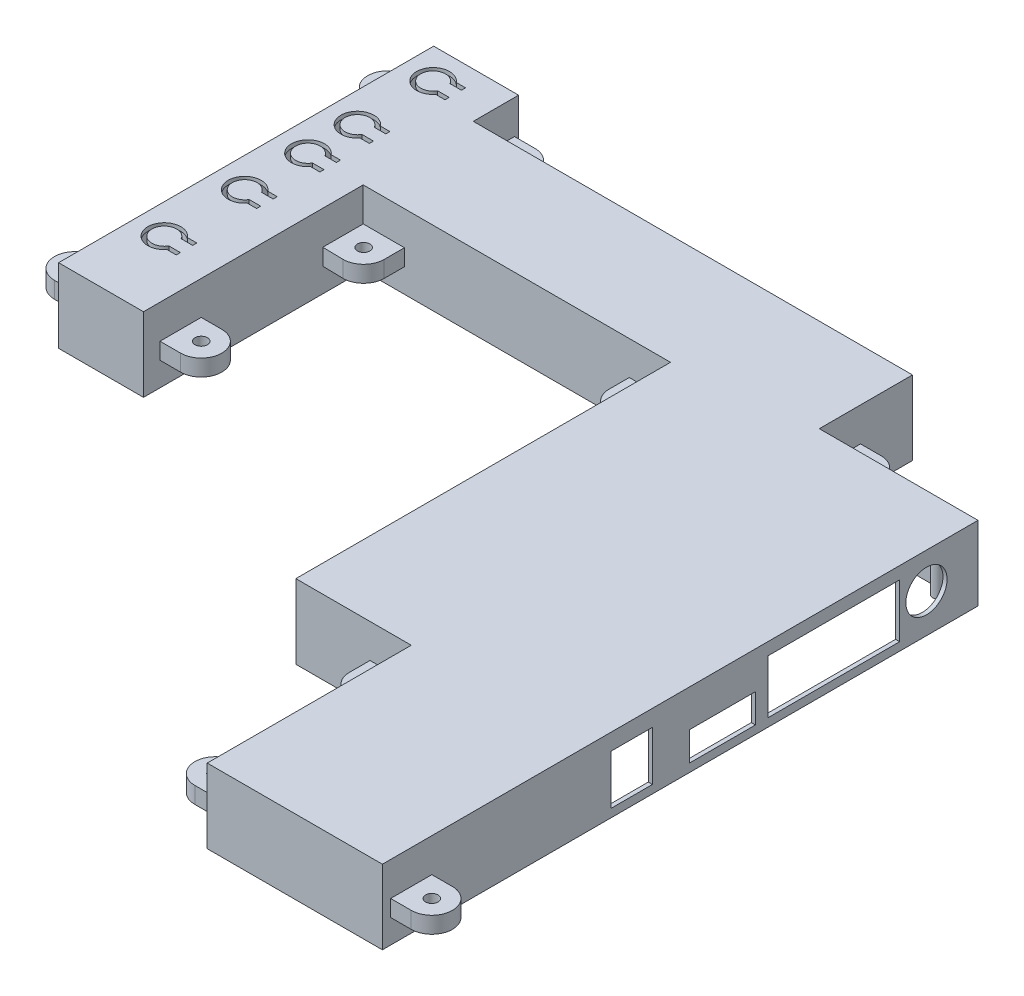
from build123d import *

# Parameters (mm, degrees)
BOSS_EXTRUDE5_DEPTH     = 18
BOSS_EXTRUDE6_START     = 17
BOSS_EXTRUDE6_DEPTH     = 1
BOSS_EXTRUDE7_START     = 5.8
SKETCH2_5_R             = 1.5
BOSS_EXTRUDE7_DEPTH     = 4
CUT_EXTRUDE1_DEPTH      = 167.833614155
CUT_EXTRUDE1_DEPTH_BACK = 167.833614155
BOSS_EXTRUDE9_START     = -1
SKETCH6_R               = 3.5
SKETCH6_R_2             = 2.25
BOSS_EXTRUDE9_DEPTH     = 6
SKETCH8_R               = 5
SKETCH8_W               = 32
SKETCH8_H               = 13
SKETCH8_W_2             = 16
SKETCH8_H_2             = 7
SKETCH8_W_3             = 10
SKETCH8_H_3             = 12
CUT_EXTRUDE2_DEPTH      = 218.268839312
CUT_EXTRUDE2_DEPTH_BACK = 6
SKETCH7_R               = 1.2
SKETCH7_R_2             = 3
SKETCH7_R_3             = 2
BOSS_EXTRUDE10_DEPTH    = 15


with BuildPart() as part:
    # Sketch2 → Boss-Extrude5 (new body)
    with BuildSketch(Plane(origin=(0, 0, 0), x_dir=(1, 0, 0), z_dir=(0, 1, 0))):
        Polygon((-76.553603822, 35.6), (-97.153603822, 35.6), (-97.153603822, 126.6), (-76.553603822, 126.6), (-76.553603822, 115.6), (30, 115.6), (30, 93), (68.5, 93), (68.5, -51.5), (26, -51.5), (26, -2), (-2, -2), (-2, 88.898979486), (-76.553603822, 88.898979486), align=None)
        Polygon((-77.553603822, 89.898979486), (-77.553603822, 36.6), (-96.157091143, 36.6), (-96.157091143, 125.6), (-77.553603822, 125.6), (-77.553603822, 114.6), (29, 114.6), (29, 92), (67.5, 92), (67.5, -50.5), (27, -50.5), (27, -1), (-1, -1), (-1, 89.898979486), align=None, mode=Mode.SUBTRACT)
    extrude(amount=BOSS_EXTRUDE5_DEPTH)

    # Sketch2_4 → Boss-Extrude6 (add)
    with BuildSketch(Plane(origin=(0, 0, 0), x_dir=(1, 0, 0), z_dir=(0, 1, 0)).offset(BOSS_EXTRUDE6_START)):
        Polygon((-77.553603822, 36.6), (-96.157091143, 36.6), (-96.157091143, 125.6), (-77.553603822, 125.6), (-77.553603822, 114.6), (29, 114.6), (29, 92), (67.5, 92), (67.5, -50.5), (27, -50.5), (27, -1), (-1, -1), (-1, 89.898979486), (-77.553603822, 89.898979486), align=None)
    extrude(amount=BOSS_EXTRUDE6_DEPTH)

    # Sketch2_5 → Boss-Extrude7 (add)
    with BuildSketch(Plane(origin=(0, 0, 0), x_dir=(1, 0, 0), z_dir=(0, 1, 0)).offset(BOSS_EXTRUDE7_START)):
        with BuildLine():
            Line((-102.153603822, 39.6), (-97.153603822, 39.6))
            Line((-97.153603822, 39.6), (-97.153603822, 49.6))
            Line((-97.153603822, 49.6), (-102.153603822, 49.6))
            ThreePointArc((-102.153603822, 49.6), (-107.153603822, 44.6), (-102.153603822, 39.6))
        make_face()
        with Locations(Location((-102.153603822, 44.6, 0), (0, 0, 270))):
            Circle(SKETCH2_5_R, mode=Mode.SUBTRACT)
        with BuildLine():
            Line((-76.553603822, 49.6), (-76.553603822, 39.6))
            Line((-76.553603822, 39.6), (-71.553603822, 39.6))
            ThreePointArc((-71.553603822, 39.6), (-66.553603822, 44.6), (-71.553603822, 49.6))
            Line((-71.553603822, 49.6), (-76.553603822, 49.6))
        make_face()
        with Locations(Location((-71.553603822, 44.6, 0), (0, 0, 270))):
            Circle(SKETCH2_5_R, mode=Mode.SUBTRACT)
        with BuildLine():
            Line((-76.553603822, 88.898979486), (-76.553603822, 79.101020514))
            Line((-76.553603822, 79.101020514), (-71.755562411, 79.004080392))
            Line((-71.755562411, 79.004080392), (-71.553603822, 79))
            ThreePointArc((-71.553603822, 79), (-68.018069917, 80.464466094), (-66.553603822, 84))
            Line((-66.553603822, 84), (-66.553603822, 88.898979486))
            Line((-66.553603822, 88.898979486), (-76.553603822, 88.898979486))
        make_face()
        with Locations(Location((-71.553603822, 84, 0), (0, 0, 270))):
            Circle(SKETCH2_5_R, mode=Mode.SUBTRACT)
        with BuildLine():
            Line((-2, 88.898979486), (-12, 88.898979486))
            Line((-12, 88.898979486), (-12, 84))
            ThreePointArc((-12, 84), (-10.535533906, 80.464466094), (-7, 79))
            Line((-7, 79), (-2, 79))
            Line((-2, 79), (-2, 88.898979486))
        make_face()
        with Locations(Location((-7, 84, 0), (0, 0, 270))):
            Circle(SKETCH2_5_R, mode=Mode.SUBTRACT)
        with BuildLine():
            Line((26, -2), (16, -2))
            Line((16, -2), (16, -7))
            ThreePointArc((16, -7), (17.464466094, -10.535533906), (21, -12))
            Line((21, -12), (26, -12))
            Line((26, -12), (26, -2))
        make_face()
        with Locations(Location((21, -7, 0), (0, 0, 270))):
            Circle(SKETCH2_5_R, mode=Mode.SUBTRACT)
        with BuildLine():
            Line((26, -49.5), (26, -39.5))
            Line((26, -39.5), (21, -39.5))
            ThreePointArc((21, -39.5), (16, -44.5), (21, -49.5))
            Line((21, -49.5), (26, -49.5))
        make_face()
        with Locations(Location((21, -44.5, 0), (0, 0, 270))):
            Circle(SKETCH2_5_R, mode=Mode.SUBTRACT)
        with BuildLine():
            Line((73.5, -39.5), (68.5, -39.5))
            Line((68.5, -39.5), (68.5, -49.5))
            Line((68.5, -49.5), (73.5, -49.5))
            ThreePointArc((73.5, -49.5), (78.5, -44.5), (73.5, -39.5))
        make_face()
        with Locations(Location((73.5, -44.5, 0), (0, 0, 270))):
            Circle(SKETCH2_5_R, mode=Mode.SUBTRACT)
        with BuildLine():
            Line((35, 103), (30, 103))
            Line((30, 103), (30, 93))
            Line((30, 93), (40, 93))
            Line((40, 93), (40, 98))
            ThreePointArc((40, 98), (38.535533906, 101.535533906), (35, 103))
        make_face()
        with Locations(Location((35, 98, 0), (0, 0, 270))):
            Circle(SKETCH2_5_R, mode=Mode.SUBTRACT)
        with BuildLine():
            Line((-102.153603822, 115.6), (-97.153603822, 115.6))
            Line((-97.153603822, 115.6), (-97.153603822, 125.6))
            Line((-97.153603822, 125.6), (-102.153603822, 125.6))
            ThreePointArc((-102.153603822, 125.6), (-107.153603822, 120.6), (-102.153603822, 115.6))
        make_face()
        with Locations(Location((-102.153603822, 120.6, 0), (0, 0, 270))):
            Circle(SKETCH2_5_R, mode=Mode.SUBTRACT)
        with BuildLine():
            Line((-71.553603822, 125.6), (-76.553603822, 125.6))
            Line((-76.553603822, 125.6), (-76.553603822, 115.6))
            Line((-76.553603822, 115.6), (-66.553603822, 115.6))
            Line((-66.553603822, 115.6), (-66.553603822, 120.6))
            ThreePointArc((-66.553603822, 120.6), (-68.018069917, 124.135533906), (-71.553603822, 125.6))
        make_face()
        with Locations(Location((-71.553603822, 120.6, 0), (0, 0, 270))):
            Circle(SKETCH2_5_R, mode=Mode.SUBTRACT)
        with Locations((73.5, 84)):
            Circle(SKETCH2_5_R)
    extrude(amount=BOSS_EXTRUDE7_DEPTH)


with BuildPart() as boss_extrude7_kept_piece:
    # of the separate pieces the step leaves, the one the design keeps (boss_extrude7_pieces_kept)
    add(part.part.solids().sort_by_distance((-76.553603822, 0, -35.6))[0])

    # Sketch5 → Cut-Extrude1 (cut, two sides)
    with BuildSketch(Plane(origin=(0, 18, 0), x_dir=(1, 0, 0), z_dir=(0, 1, 0))) as cut_extrude1_sk:
        with BuildLine():
            Line((-86.781104823, 121.7), (-84.514671921, 121.7))
            Line((-84.514671921, 121.7), (-84.514671921, 120.7))
            Line((-84.514671921, 120.7), (-87.305527611, 120.7))
            ThreePointArc((-87.305527611, 120.7), (-92.903603822, 119.2), (-87.305527611, 117.7))
            Line((-87.305527611, 117.7), (-84.514671921, 117.7))
            Line((-84.514671921, 117.7), (-84.514671921, 116.7))
            Line((-84.514671921, 116.7), (-86.781104823, 116.7))
            ThreePointArc((-86.781104823, 116.7), (-93.903603822, 119.2), (-86.781104823, 121.7))
        make_face()
        with BuildLine():
            Line((-86.781104823, 103.35), (-84.514671921, 103.35))
            Line((-84.514671921, 103.35), (-84.514671921, 102.35))
            Line((-84.514671921, 102.35), (-87.305527611, 102.35))
            ThreePointArc((-87.305527611, 102.35), (-92.903603822, 100.85), (-87.305527611, 99.35))
            Line((-87.305527611, 99.35), (-84.514671921, 99.35))
            Line((-84.514671921, 99.35), (-84.514671921, 98.35))
            Line((-84.514671921, 98.35), (-86.781104823, 98.35))
            ThreePointArc((-86.781104823, 98.35), (-93.903603822, 100.85), (-86.781104823, 103.35))
        make_face()
        with BuildLine():
            Line((-86.781104823, 91.35), (-84.514671921, 91.35))
            Line((-84.514671921, 91.35), (-84.514671921, 90.35))
            Line((-84.514671921, 90.35), (-87.305527611, 90.35))
            ThreePointArc((-87.305527611, 90.35), (-92.903603822, 88.85), (-87.305527611, 87.35))
            Line((-87.305527611, 87.35), (-84.514671921, 87.35))
            Line((-84.514671921, 87.35), (-84.514671921, 86.35))
            Line((-84.514671921, 86.35), (-86.781104823, 86.35))
            ThreePointArc((-86.781104823, 86.35), (-93.903603822, 88.85), (-86.781104823, 91.35))
        make_face()
        with BuildLine():
            Line((-86.781104823, 76), (-84.514671921, 76))
            Line((-84.514671921, 76), (-84.514671921, 75))
            Line((-84.514671921, 75), (-87.305527611, 75))
            ThreePointArc((-87.305527611, 75), (-92.903603822, 73.5), (-87.305527611, 72))
            Line((-87.305527611, 72), (-84.514671921, 72))
            Line((-84.514671921, 72), (-84.514671921, 71))
            Line((-84.514671921, 71), (-86.781104823, 71))
            ThreePointArc((-86.781104823, 71), (-93.903603822, 73.5), (-86.781104823, 76))
        make_face()
        with BuildLine():
            Line((-86.781104823, 56.5), (-84.514671921, 56.5))
            Line((-84.514671921, 56.5), (-84.514671921, 55.5))
            Line((-84.514671921, 55.5), (-87.305527611, 55.5))
            ThreePointArc((-87.305527611, 55.5), (-92.903603822, 54), (-87.305527611, 52.5))
            Line((-87.305527611, 52.5), (-84.514671921, 52.5))
            Line((-84.514671921, 52.5), (-84.514671921, 51.5))
            Line((-84.514671921, 51.5), (-86.781104823, 51.5))
            ThreePointArc((-86.781104823, 51.5), (-93.903603822, 54), (-86.781104823, 56.5))
        make_face()
    extrude(amount=CUT_EXTRUDE1_DEPTH, mode=Mode.SUBTRACT)
    extrude(cut_extrude1_sk.sketch, amount=-CUT_EXTRUDE1_DEPTH_BACK, mode=Mode.SUBTRACT)

    # Sketch6 → Boss-Extrude9 (add)
    with BuildSketch(Plane(origin=(0, 18, 0), x_dir=(1, 0, 0), z_dir=(0, 1, 0)).offset(BOSS_EXTRUDE9_START)):
        with Locations(Location((-89.903603822, 109.25, 0), (0, 0, 270))):
            Circle(SKETCH6_R)
        with Locations(Location((-89.903603822, 109.25, 0), (0, 0, 270))):
            Circle(SKETCH6_R_2, mode=Mode.SUBTRACT)
        with Locations(Location((-89.903603822, 63, 0), (0, 0, 270))):
            Circle(SKETCH6_R)
        with Locations(Location((-89.903603822, 63, 0), (0, 0, 270))):
            Circle(SKETCH6_R_2, mode=Mode.SUBTRACT)
    extrude(amount=-BOSS_EXTRUDE9_DEPTH)

    # Sketch8 → Cut-Extrude2 (cut, two sides)
    with BuildSketch(Plane(origin=(68.5, 0, 0), x_dir=(0, 0, -1), z_dir=(1, 0, 0))) as cut_extrude2_sk:
        with Locations((80.5, 9.4)):
            Circle(SKETCH8_R)
        with Locations((58, 8.5)):
            Rectangle(SKETCH8_W, SKETCH8_H)
        with Locations((31, 5.5)):
            Rectangle(SKETCH8_W_2, SKETCH8_H_2)
        with Locations((9, 8)):
            Rectangle(SKETCH8_W_3, SKETCH8_H_3)
    extrude(amount=CUT_EXTRUDE2_DEPTH, mode=Mode.SUBTRACT)
    extrude(cut_extrude2_sk.sketch, amount=-CUT_EXTRUDE2_DEPTH_BACK, mode=Mode.SUBTRACT)

    # Sketch7 → Boss-Extrude10 (add)
    with BuildSketch(Plane.XZ.offset(-17)):
        with Locations(Location((1.2, -10.7, 0), (0, 0, 90))):
            Circle(SKETCH7_R)
        with Locations(Location((2, -89, 0), (0, 0, 90))):
            Circle(SKETCH7_R)
        with Locations(Location((63.3, -88.4, 0), (0, 0, 90))):
            Circle(SKETCH7_R)
        with Locations(Location((63, -1.6, 0), (0, 0, 90))):
            Circle(SKETCH7_R)
        with Locations(Location((52.066768514, -32.967079536, 0), (0, 0, 90))):
            Circle(SKETCH7_R_2)
        with Locations(Location((3, -52, 0), (0, 0, 90))):
            Circle(SKETCH7_R_3)
    extrude(amount=BOSS_EXTRUDE10_DEPTH)


solid = boss_extrude7_kept_piece.part
